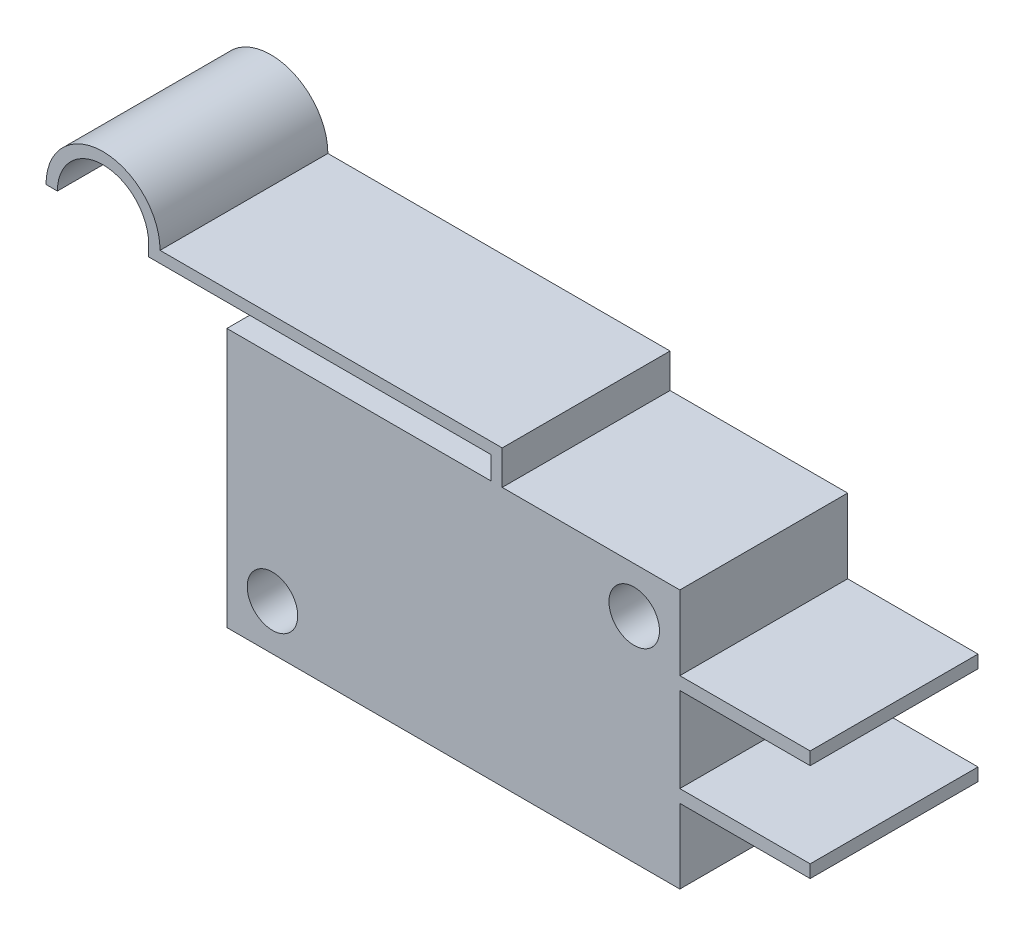
from build123d import *

# Parameters (mm, degrees)
SKETCH_3_W          = 27.8
SKETCH_3_H          = 15.9
EXTRUDE_1_DEPTH     = 10.3
SKETCH_4_R          = 1.55
CUT_EXTRUDE_1_DEPTH = 10.3
SKETCH_5_W          = 8
SKETCH_5_H          = 0.784988322
EXTRUDE_2_DEPTH     = 10.3
EXTRUDE_3_DEPTH     = 10.3


with BuildPart() as part:
    # 草图3 → 凸台-拉伸1 (new body)
    with BuildSketch(Plane.XY):
        with Locations((-13.9, 7.95)):
            Rectangle(SKETCH_3_W, SKETCH_3_H)
    extrude(amount=EXTRUDE_1_DEPTH)

    # 草图4 → 切除-拉伸1 (cut)
    with BuildSketch(Plane.XY.offset(10.3)):
        with Locations((-2.8, 13.1)):
            Circle(SKETCH_4_R)
        with Locations((-25, 2.8)):
            Circle(SKETCH_4_R)
    extrude(amount=-CUT_EXTRUDE_1_DEPTH, mode=Mode.SUBTRACT)

    # 草图5 → 凸台-拉伸2 (add)
    with BuildSketch(Plane.XY.offset(10.3)):
        with Locations((4, 10.95)):
            Rectangle(SKETCH_5_W, SKETCH_5_H)
        with Locations((4, 4.95)):
            Rectangle(SKETCH_5_W, SKETCH_5_H)
    extrude(amount=-EXTRUDE_2_DEPTH)

    # 草图6 → 凸台-拉伸3 (add)
    with BuildSketch(Plane.XY.offset(10.3)):
        with BuildLine():
            Line((-31.9, 18), (-22.452464215, 18))
            Line((-22.452464215, 18), (-10.9, 18))
            Line((-10.9, 18), (-10.9, 15.9))
            Line((-10.9, 15.9), (-11.6, 15.9))
            Line((-11.6, 15.9), (-11.6, 17.3))
            Line((-11.6, 17.3), (-31.896338759, 17.3))
            Line((-31.896338759, 17.3), (-32.6, 17.3))
            Line((-32.6, 17.3), (-32.6, 18))
            ThreePointArc((-32.6, 18), (-35.4, 20.8), (-38.2, 18))
            Line((-38.2, 18), (-38.9, 18))
            ThreePointArc((-38.9, 18), (-35.4, 21.5), (-31.9, 18))
        make_face()
    extrude(amount=-EXTRUDE_3_DEPTH)


solid = part.part
